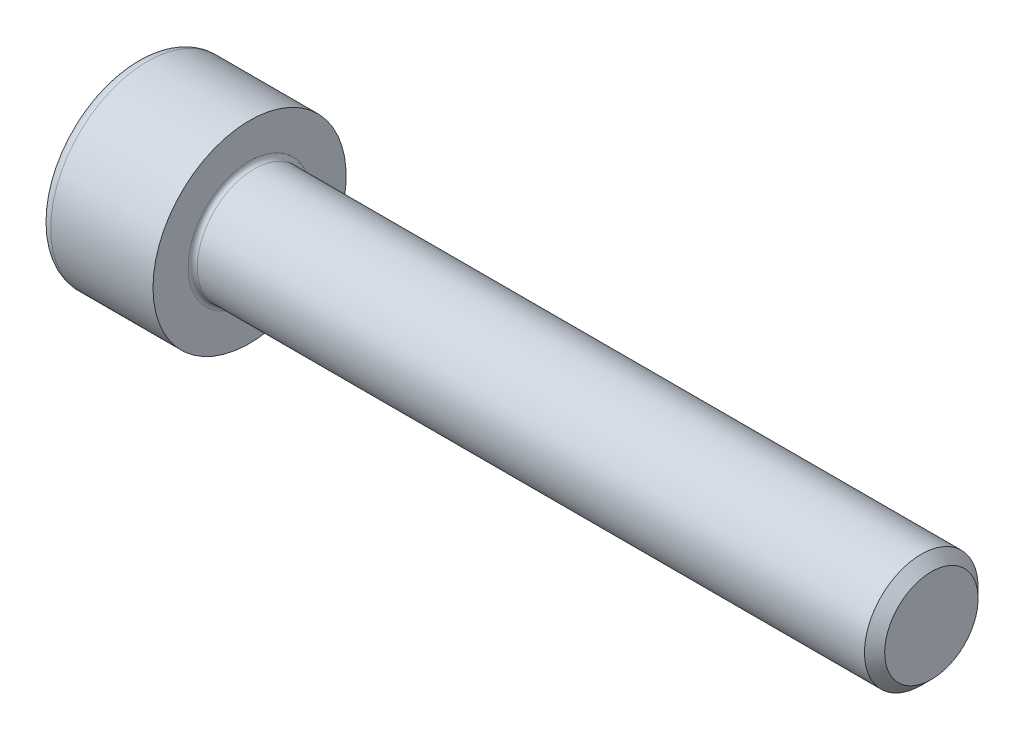
from build123d import *

# Parameters (mm, degrees)
FILLET1_R   = 0.2
FILLET2_R   = 0.5
HEX_2_DEPTH = 2.5


with BuildPart() as part:
    # BodySke → Base-Revolve (revolve)
    with BuildSketch(Plane.XY):
        Polygon((0, 0), (0, 4.25), (5, 4.25), (5, 2.5), (34.555, 2.5), (35, 2.055), (35, 0), align=None)
    revolve(axis=Axis((-31.75, 0, 0), (1, 0, 0)))

    # Fillet1
    fillet1_edges = [part.edges().sort_by_distance(p)[0] for p in [
        (5, -2.5, 0),
    ]]
    fillet(fillet1_edges, radius=FILLET1_R)

    # Fillet2
    fillet2_edges = [part.edges().sort_by_distance(p)[0] for p in [
        (0, -4.25, 0),
    ]]
    fillet(fillet2_edges, radius=FILLET2_R)

    # Sketch2 → Hex-PreBroach (revolve, cut)
    with BuildSketch(Plane.XY):
        Polygon((0, 2.01), (2.5, 2.01), (3.660474041, 0), (0, 0), align=None)
    revolve(axis=Axis((0, 0, 0), (1, 0, 0)), mode=Mode.SUBTRACT)

    # Sketch3 → Hex 2 (cut)
    with BuildSketch(Plane(origin=(0, 0, 0), x_dir=(0, 0.5, 0.866025404), z_dir=(-1, 0, 0))):
        Polygon((1.160474041, 2.01), (-1.160474041, 2.01), (-2.320948082, 0), (-1.160474041, -2.01), (1.160474041, -2.01), (2.320948082, 0), align=None)
    extrude(amount=-HEX_2_DEPTH, mode=Mode.SUBTRACT)


solid = part.part
